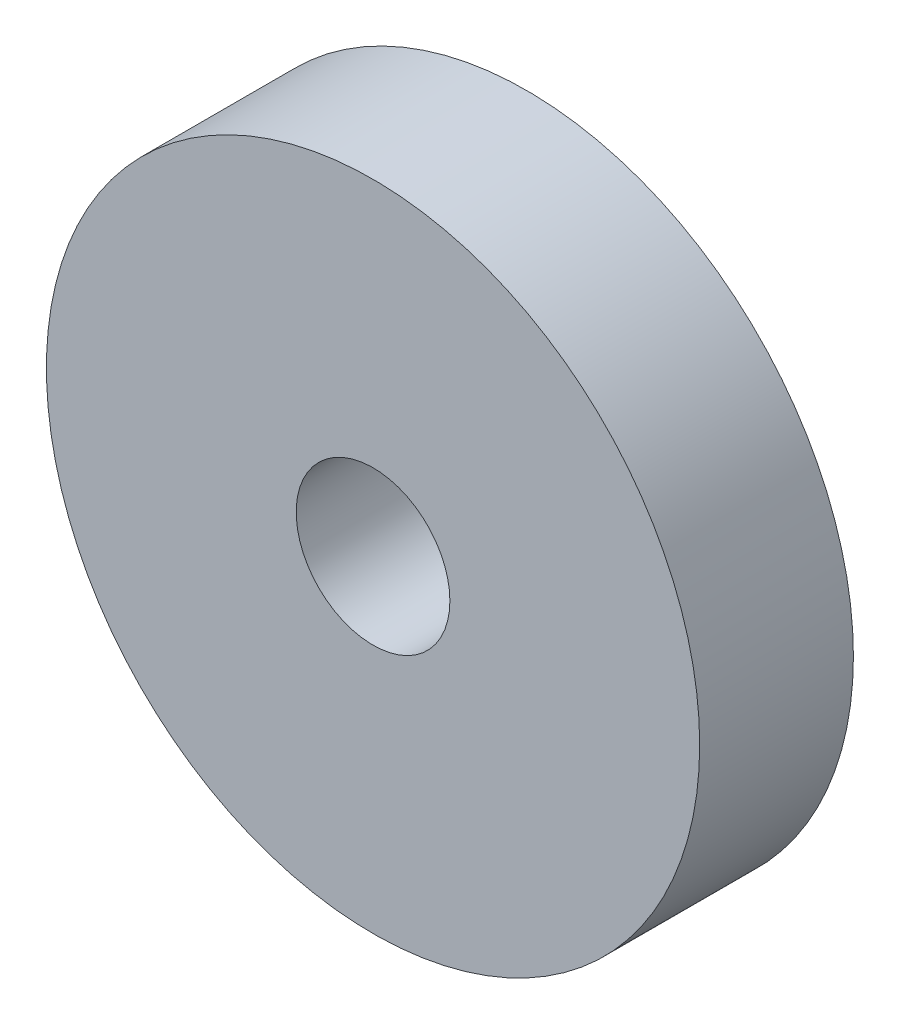
from build123d import *

# Parameters (mm, degrees)
SKETCH1_R           = 2.125
SKETCH1_R_2         = 0.5
BOSS_EXTRUDE1_DEPTH = 1


with BuildPart() as part:
    # Sketch1 → Boss-Extrude1 (new body)
    with BuildSketch(Plane.XY):
        Circle(SKETCH1_R)
        Circle(SKETCH1_R_2, mode=Mode.SUBTRACT)
    extrude(amount=BOSS_EXTRUDE1_DEPTH)


solid = part.part
